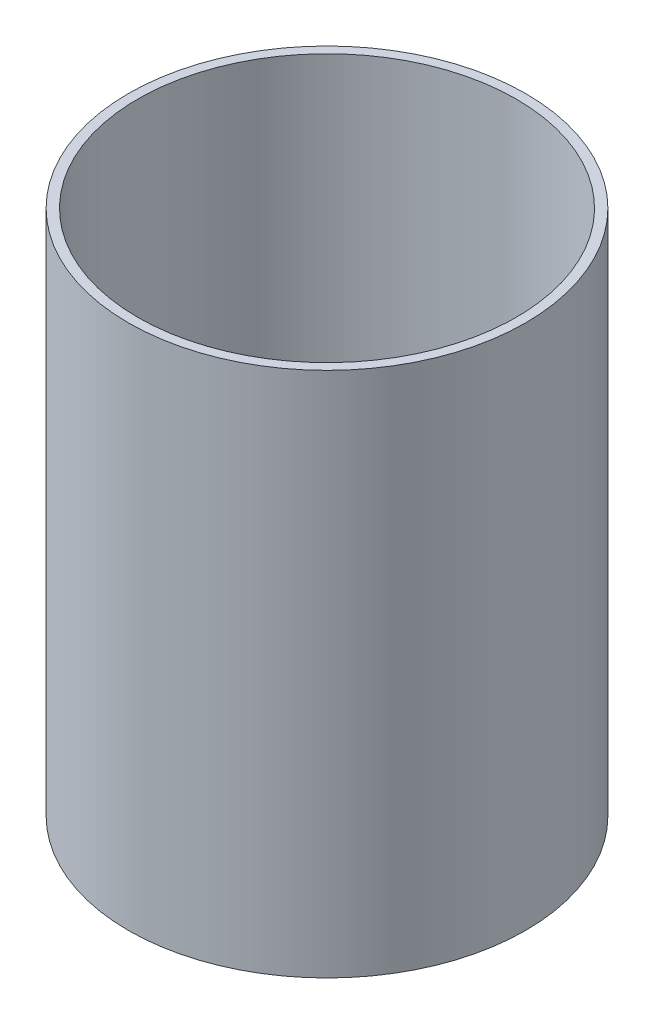
from build123d import *

# Parameters (mm, degrees)
SKETCH_1_R          = 630
EXTRUDE_1_DEPTH     = 1669
SKETCH_2_R          = 600
CUT_EXTRUDE_1_DEPTH = 2914


with BuildPart() as part:
    # 草图1 → 凸台-拉伸1 (new body)
    with BuildSketch(Plane(origin=(0, 0, 0), x_dir=(1, 0, 0), z_dir=(0, 1, 0))):
        Circle(SKETCH_1_R)
    extrude(amount=EXTRUDE_1_DEPTH)

    # 草图2 → 切除-拉伸1 (cut)
    with BuildSketch(Plane(origin=(0, 1669, 0), x_dir=(1, 0, 0), z_dir=(0, 1, 0))):
        Circle(SKETCH_2_R)
    extrude(amount=-CUT_EXTRUDE_1_DEPTH, mode=Mode.SUBTRACT)


solid = part.part
